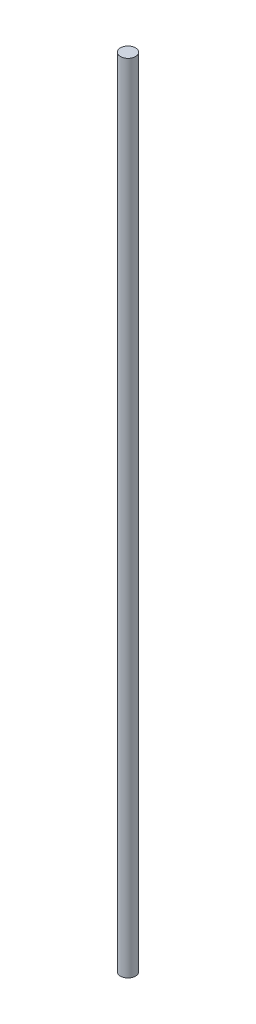
from build123d import *

# Parameters (mm, degrees)
SKETCH1_R           = 0.95
BOSS_EXTRUDE1_DEPTH = 100


with BuildPart() as part:
    # Sketch1 → Boss-Extrude1 (new body)
    with BuildSketch(Plane(origin=(0, 0, 0), x_dir=(1, 0, 0), z_dir=(0, 1, 0))):
        Circle(SKETCH1_R)
    extrude(amount=BOSS_EXTRUDE1_DEPTH)


solid = part.part
